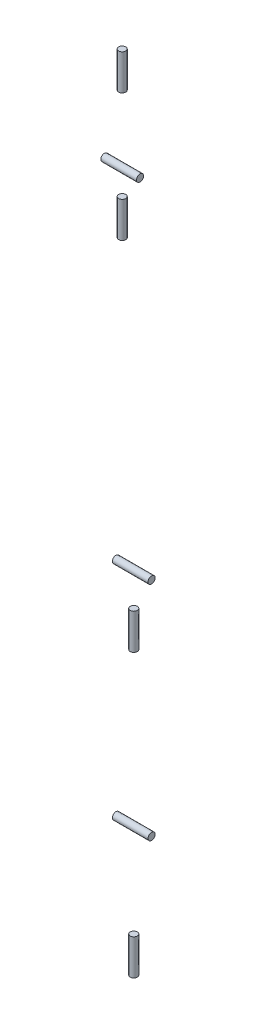
from build123d import *

# Parameters (mm, degrees)
SKETCH1_R           = 2.5
AXIS_0_AX12_DEPTH   = 25
SKETCH2_R           = 2.5
AXIS_1_EX106_DEPTH  = 12.5
SKETCH3_R           = 2.5
AXIS_2_RX64_1_DEPTH = 12.5
SKETCH4_R           = 2.5
AXIS_3_RX64_2_DEPTH = 12.5
SKETCH5_R           = 2.5
AXIS_4_RX28_1_DEPTH = 12.5
SKETCH6_R           = 2.5
AXIS_5_RX28_2_DEPTH = 12.5
SKETCH7_R           = 2.5
BOSS_EXTRUDE1_DEPTH = 12.5


with BuildPart() as part:
    # Sketch1 → Axis 0 - AX12 (new body)
    with BuildSketch(Plane(origin=(0, 0, 0), x_dir=(1, 0, 0), z_dir=(0, 1, 0))):
        Circle(SKETCH1_R)
    extrude(amount=AXIS_0_AX12_DEPTH)


with BuildPart() as body_2:
    # Sketch2 → Axis 1 - EX106 (new body, symmetric)
    with BuildSketch(Plane(origin=(0, 0, 0), x_dir=(0, 0, -1), z_dir=(1, 0, 0))):
        with Locations((0, 90.525)):
            Circle(SKETCH2_R)
    extrude(amount=AXIS_1_EX106_DEPTH, both=True)


with BuildPart() as body_3:
    # Sketch3 → Axis 2 - RX64 1 (new body, symmetric)
    with BuildSketch(Plane(origin=(0, 210.225, 0), x_dir=(-1, 0, 0), z_dir=(0, 1, 0))):
        Circle(SKETCH3_R)
    extrude(amount=AXIS_2_RX64_1_DEPTH, both=True)


with BuildPart() as body_4:
    # Sketch4 → Axis 3 - RX64 2 (new body, symmetric)
    with BuildSketch(Plane(origin=(0, 0, 0), x_dir=(0, 0, -1), z_dir=(1, 0, 0))):
        with Locations((0, 246.225)):
            Circle(SKETCH4_R)
    extrude(amount=AXIS_3_RX64_2_DEPTH, both=True)


with BuildPart() as body_5:
    # Sketch5 → Axis 4 - RX28 1 (new body, symmetric)
    with BuildSketch(Plane(origin=(0, 464.425, 0), x_dir=(-1, 0, 0), z_dir=(0, 1, 0))):
        with Locations((0, 8.1)):
            Circle(SKETCH5_R)
    extrude(amount=AXIS_4_RX28_1_DEPTH, both=True)


with BuildPart() as body_6:
    # Sketch6 → Axis 5 - RX28 2 (new body, symmetric)
    with BuildSketch(Plane(origin=(0, 0, 0), x_dir=(0, 0, -1), z_dir=(1, 0, 0))):
        with Locations((-8.1, 494.425)):
            Circle(SKETCH6_R)
    extrude(amount=AXIS_5_RX28_2_DEPTH, both=True)


with BuildPart() as body_7:
    # Sketch7 → Boss-Extrude1 (new body, symmetric)
    with BuildSketch(Plane(origin=(0, 554.025, 0), x_dir=(-1, 0, 0), z_dir=(0, 1, 0))):
        with Locations((0, 8.1)):
            Circle(SKETCH7_R)
    extrude(amount=BOSS_EXTRUDE1_DEPTH, both=True)


solid = Compound([part.part, body_2.part, body_3.part, body_4.part, body_5.part, body_6.part, body_7.part])
